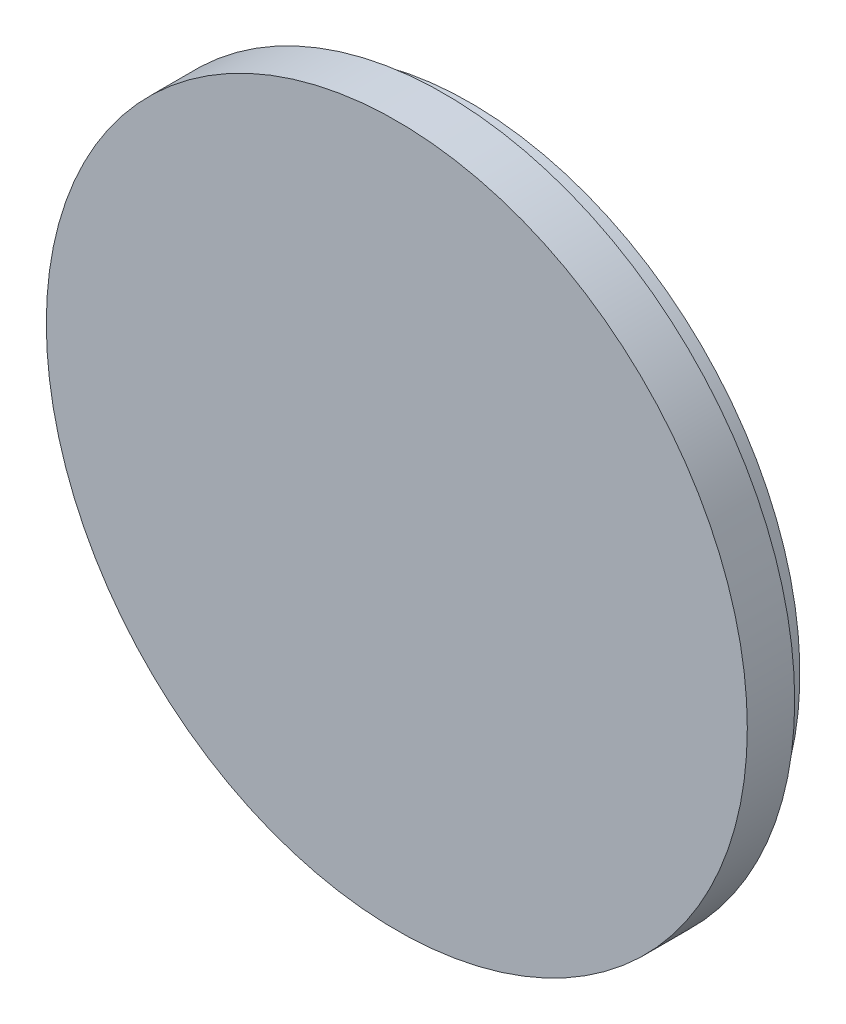
from build123d import *

# Parameters (mm, degrees)
SKETCH1_R           = 27
BOSS_EXTRUDE1_DEPTH = 3.65
SKETCH3_R           = 25.4
BOSS_EXTRUDE3_DEPTH = 2


with BuildPart() as part:
    # Sketch1 → Boss-Extrude1 (new body)
    with BuildSketch(Plane.XY):
        Circle(SKETCH1_R)
    extrude(amount=BOSS_EXTRUDE1_DEPTH)

    # Sketch3 → Boss-Extrude3 (add)
    with BuildSketch(Plane(origin=(0, 0, 0), x_dir=(-1, 0, 0), z_dir=(0, 0, -1))):
        Circle(SKETCH3_R)
    extrude(amount=BOSS_EXTRUDE3_DEPTH)


solid = part.part
